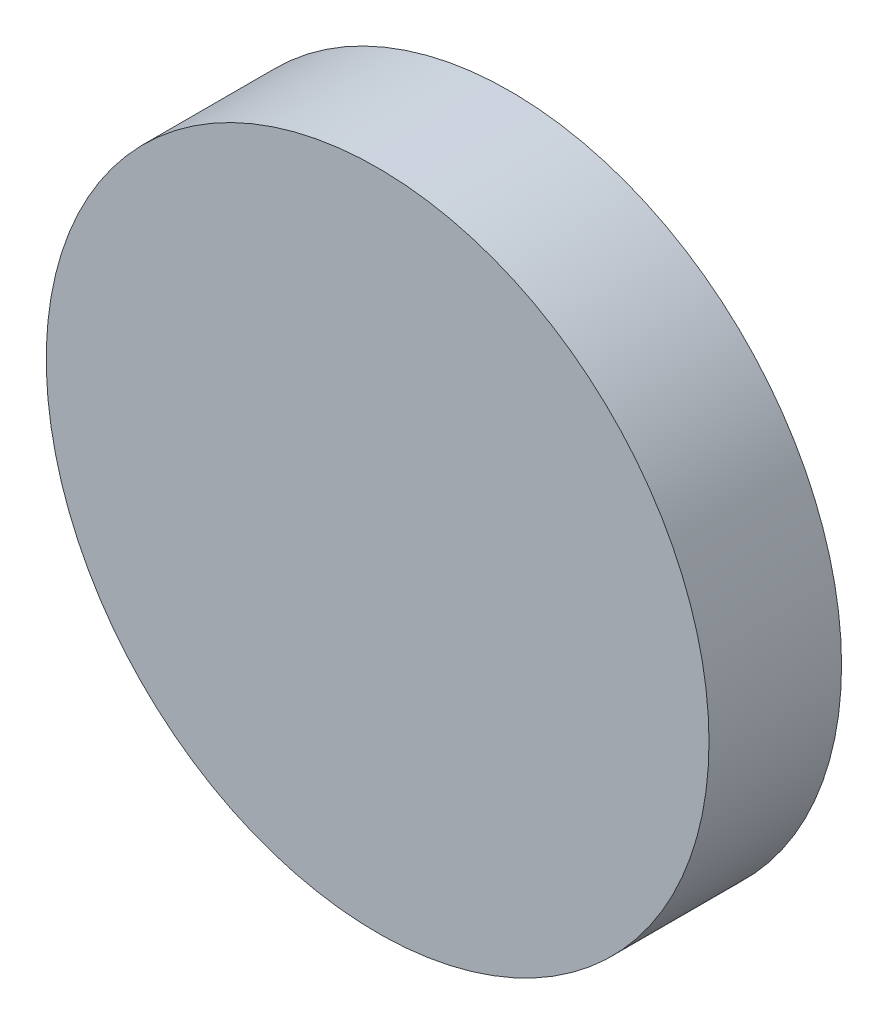
from build123d import *

# Parameters (mm, degrees)
SKETCH1_R           = 30
BOSS_EXTRUDE1_DEPTH = 12


with BuildPart() as part:
    # Sketch1 → Boss-Extrude1 (new body)
    with BuildSketch(Plane.XY):
        Circle(SKETCH1_R)
    extrude(amount=BOSS_EXTRUDE1_DEPTH)


solid = part.part
